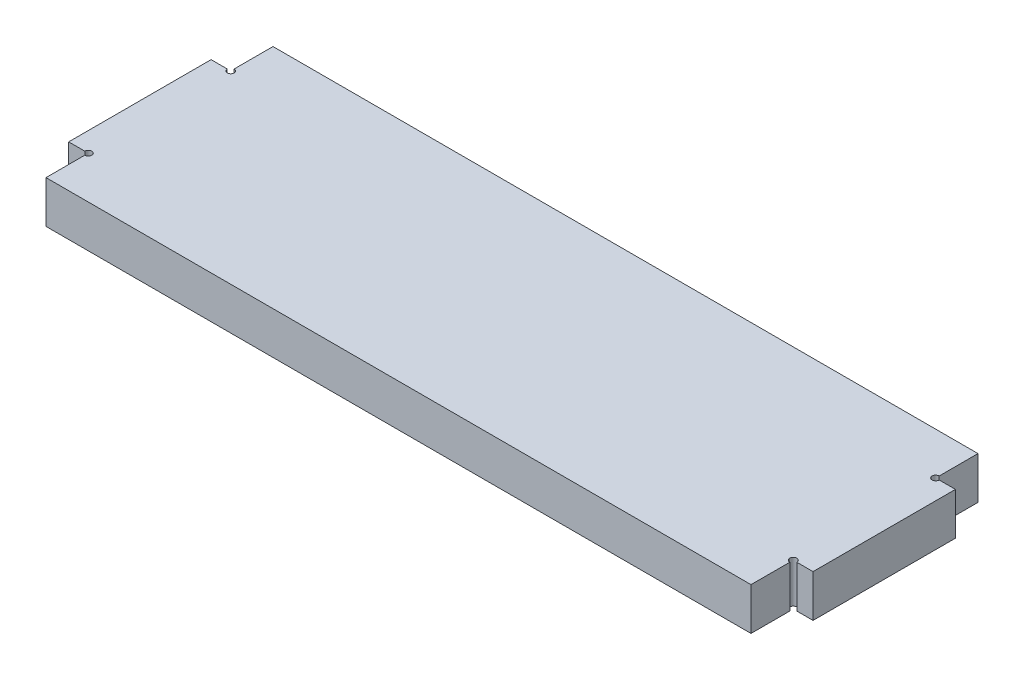
from build123d import *

# Parameters (mm, degrees)
BOSS_EXTRUDE1_DEPTH = 3


with BuildPart() as part:
    # Sketch1 → Boss-Extrude1 (new body)
    with BuildSketch(Plane(origin=(0, 0, 0), x_dir=(1, 0, 0), z_dir=(0, 1, 0))):
        with BuildLine():
            Line((0.25, 5.332122905), (1.4, 5.332122905))
            Line((1.4, 5.332122905), (1.4, -4.767877095))
            Line((1.4, -4.767877095), (0.25, -4.767877095))
            ThreePointArc((0.25, -4.767877095), (-0.176776695, -4.5911004), (0, -5.017877095))
            Line((0, -5.017877095), (0, -7.767877095))
            Line((0, -7.767877095), (-50, -7.767877095))
            Line((-50, -7.767877095), (-50, -5.017877095))
            ThreePointArc((-50, -5.017877095), (-49.823223305, -4.5911004), (-50.25, -4.767877095))
            Line((-50.25, -4.767877095), (-51.390981623, -4.767877095))
            Line((-51.390981623, -4.767877095), (-51.390981623, 5.332122905))
            Line((-51.390981623, 5.332122905), (-50.245259273, 5.332122905))
            ThreePointArc((-50.245259273, 5.332122905), (-49.826575505, 5.15869841), (-50, 5.577382178))
            Line((-50, 5.577382178), (-50, 8.332122905))
            Line((-50, 8.332122905), (0, 8.332122905))
            Line((0, 8.332122905), (0, 5.582122905))
            ThreePointArc((0, 5.582122905), (-0.176776695, 5.15534621), (0.25, 5.332122905))
        make_face()
    extrude(amount=BOSS_EXTRUDE1_DEPTH)


solid = part.part
